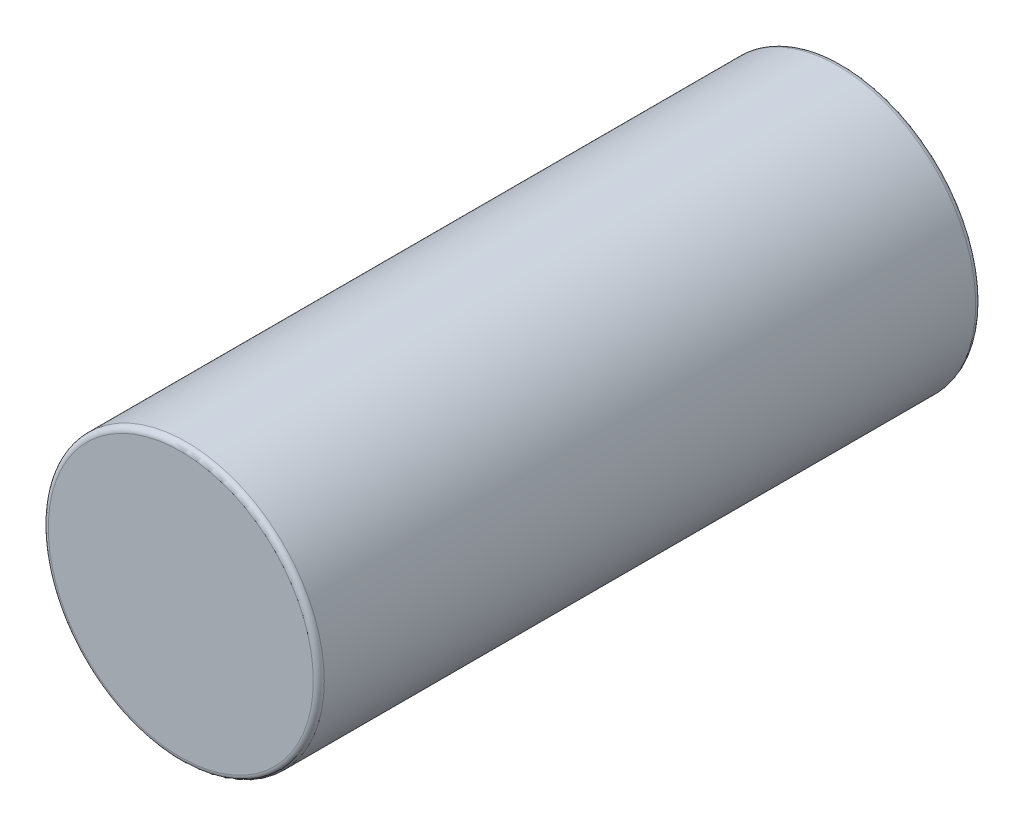
from build123d import *

# Parameters (mm, degrees)
SKETCH1_R           = 2.5
BOSS_EXTRUDE1_DEPTH = 12
FILLET1_R           = 0.1


with BuildPart() as part:
    # Sketch1 → Boss-Extrude1 (new body)
    with BuildSketch(Plane.XY):
        Circle(SKETCH1_R)
    extrude(amount=-BOSS_EXTRUDE1_DEPTH)

    # Fillet1
    fillet1_edges = [part.edges().sort_by_distance(p)[0] for p in [
        (-2.5, 0, 0),
        (-2.5, 0, -12),
    ]]
    fillet(fillet1_edges, radius=FILLET1_R)


solid = part.part
